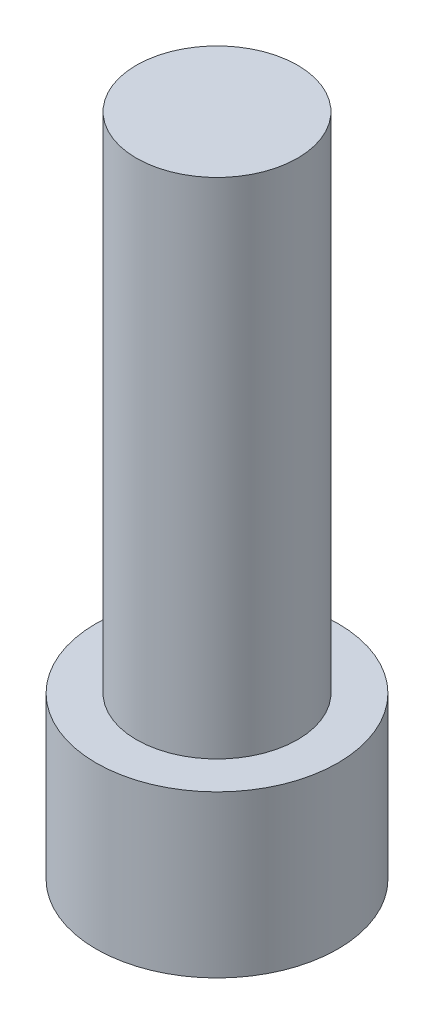
from build123d import *

# Parameters (mm, degrees)
SKETCH1_R           = 4
BOSS_EXTRUDE1_DEPTH = 25
SKETCH2_R           = 6
SKETCH2_R_2         = 4
BOSS_EXTRUDE2_DEPTH = 2
SKETCH3_R           = 6
BOSS_EXTRUDE3_DEPTH = 6


with BuildPart() as part:
    # Sketch1 → Boss-Extrude1 (new body)
    with BuildSketch(Plane(origin=(0, 0, 0), x_dir=(1, 0, 0), z_dir=(0, 1, 0))):
        Circle(SKETCH1_R)
    extrude(amount=BOSS_EXTRUDE1_DEPTH)

    # Sketch2 → Boss-Extrude2 (add)
    with BuildSketch(Plane.XZ):
        Circle(SKETCH2_R)
        Circle(SKETCH2_R_2, mode=Mode.SUBTRACT)
        Circle(SKETCH2_R_2)
        Circle(SKETCH2_R_2)
    extrude(amount=BOSS_EXTRUDE2_DEPTH)

    # Sketch3 → Boss-Extrude3 (add)
    with BuildSketch(Plane.XZ.offset(2)):
        Circle(SKETCH3_R)
        Polygon((4.618802154, 0), (2.309401077, 4), (-2.309401077, 4), (-4.618802154, 0), (-2.309401077, -4), (2.309401077, -4), align=None, mode=Mode.SUBTRACT)
    extrude(amount=BOSS_EXTRUDE3_DEPTH)


solid = part.part
